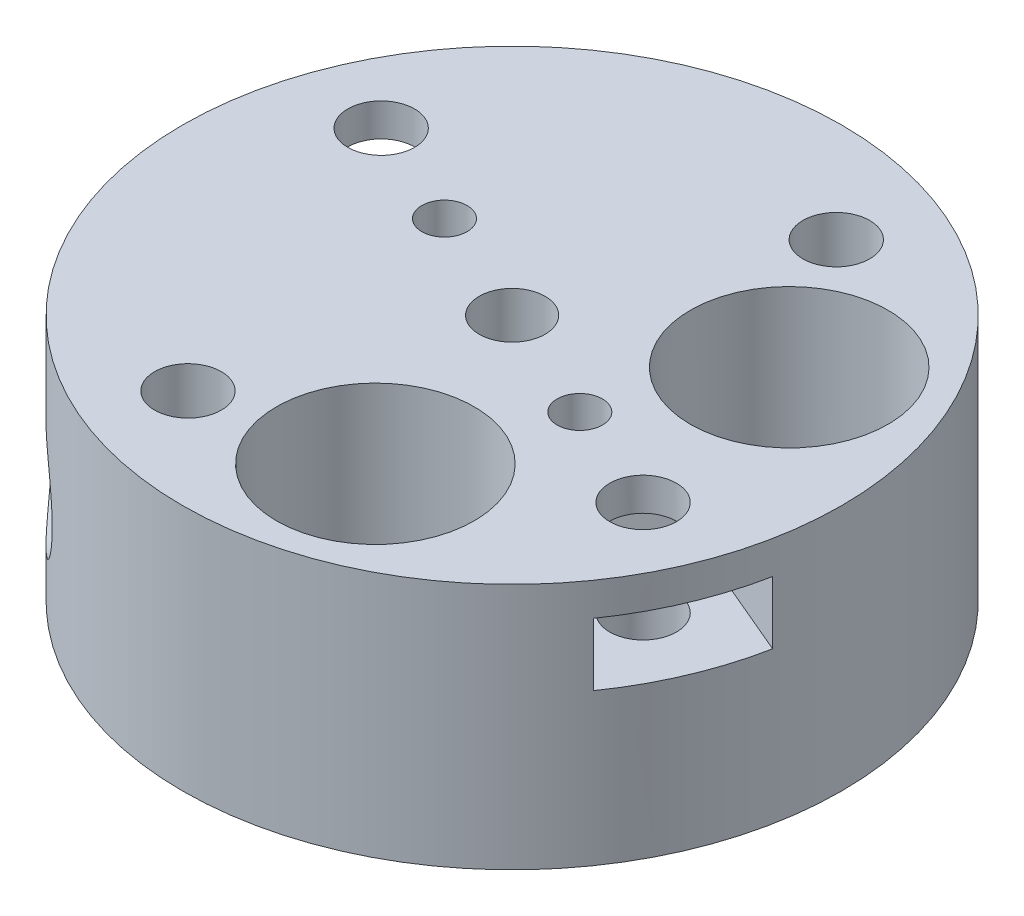
from build123d import *

# Parameters (mm, degrees)
SKETCH1_R               = 20
BOSS_EXTRUDE1_DEPTH     = 7.5
SKETCH4_R               = 5.125
CUT_EXTRUDE2_DEPTH      = 12.15
SKETCH5_R               = 2
CUT_EXTRUDE3_DEPTH      = 1
CUT_EXTRUDE3_DEPTH_BACK = 16
SKETCH2_R               = 2.025
CUT_EXTRUDE1_DEPTH      = 16
CIRPATTERN1_COUNT       = 4
SKETCH6_R               = 1.525
CUT_EXTRUDE4_DEPTH      = 21
CUT_EXTRUDE5_START      = -20
SKETCH7_R               = 3.25
CUT_EXTRUDE5_DEPTH      = 8
CUT_EXTRUDE11_START     = -6.5
CUT_EXTRUDE11_DEPTH     = 2.9
CIRPATTERN2_COUNT       = 2
CIRPATTERN2_ANGLE       = 135
CUT_EXTRUDE7_START      = 5.5
CUT_EXTRUDE7_DEPTH      = 3.8
CIRPATTERN3_COUNT       = 2
CUT_EXTRUDE12_START     = -16.0000001
SKETCH10_R              = 6
CUT_EXTRUDE12_DEPTH     = 17.0000002
CIRPATTERN4_COUNT       = 2
CIRPATTERN4_ANGLE       = 100
CUT_EXTRUDE13_START     = -16.0000001
SKETCH11_R              = 1.375
CUT_EXTRUDE13_DEPTH     = 17.0000002
SKETCH13_R              = 2.375
CUT_EXTRUDE24_DEPTH     = 12
CIRPATTERN5_COUNT       = 2


with BuildPart() as part:
    # Sketch1 → Boss-Extrude1 (new body, symmetric)
    with BuildSketch(Plane(origin=(0, 0, 0), x_dir=(1, 0, 0), z_dir=(0, 1, 0))):
        Circle(SKETCH1_R)
    extrude(amount=BOSS_EXTRUDE1_DEPTH, both=True)

    # Sketch4 → Cut-Extrude2 (cut)
    with BuildSketch(Plane.XZ.offset(7.5)):
        Circle(SKETCH4_R)
    extrude(amount=-CUT_EXTRUDE2_DEPTH, mode=Mode.SUBTRACT)

    # Sketch5 → Cut-Extrude3 (cut, two sides)
    with BuildSketch(Plane(origin=(0, 7.5, 0), x_dir=(1, 0, 0), z_dir=(0, 1, 0))) as cut_extrude3_sk:
        Circle(SKETCH5_R)
    extrude(amount=CUT_EXTRUDE3_DEPTH, mode=Mode.SUBTRACT)
    extrude(cut_extrude3_sk.sketch, amount=-CUT_EXTRUDE3_DEPTH_BACK, mode=Mode.SUBTRACT)

    # Sketch2 → Cut-Extrude1 (cut, through all)
    with BuildSketch(Plane(origin=(0, 7.5, 0), x_dir=(1, 0, 0), z_dir=(0, 1, 0))):
        with Locations((-13.807572802, 5.860966927)):
            Circle(SKETCH2_R)
    cut_extrude1 = extrude(amount=-CUT_EXTRUDE1_DEPTH, mode=Mode.SUBTRACT)

    # CirPattern1: Cut-Extrude1 ×4 about axis
    cirpattern1_axis = Axis((0, 0, 0), (0, 1, 0))
    for i in range(1, CIRPATTERN1_COUNT):
        add(cut_extrude1.rotate(cirpattern1_axis, i * 360 / CIRPATTERN1_COUNT), mode=Mode.SUBTRACT)

    # Sketch6 → Cut-Extrude4 (cut, through all)
    with BuildSketch(Plane.XY):
        with Locations((0, -1.35)):
            Circle(SKETCH6_R)
    cut_extrude4 = extrude(amount=-CUT_EXTRUDE4_DEPTH, mode=Mode.SUBTRACT)

    # Sketch7 → Cut-Extrude5 (cut)
    with BuildSketch(Plane.XY.offset(CUT_EXTRUDE5_START)):
        with Locations((0, -1.35)):
            Circle(SKETCH7_R)
    cut_extrude5 = extrude(amount=CUT_EXTRUDE5_DEPTH, mode=Mode.SUBTRACT)

    # Sketch9 → Cut-Extrude11 (cut)
    with BuildSketch(Plane.XY.offset(CUT_EXTRUDE11_START)):
        Polygon((3.15, -3.168653348), (3.15, 0.468653348), (0, 2.287306696), (-3.15, 0.468653348), (-3.15, -3.168653348), (-3.15, -7.685074736), (3.15, -7.685074736), align=None)
    cut_extrude11 = extrude(amount=-CUT_EXTRUDE11_DEPTH, mode=Mode.SUBTRACT)

    # CirPattern2: Cut-Extrude4, Cut-Extrude5, Cut-Extrude11 ×2 about axis
    cirpattern2_axis = Axis((0, 0, 0), (0, 1, 0))
    for i in range(1, CIRPATTERN2_COUNT):
        add(cut_extrude4.rotate(cirpattern2_axis, i * CIRPATTERN2_ANGLE / (CIRPATTERN2_COUNT - 1)), mode=Mode.SUBTRACT)
        add(cut_extrude5.rotate(cirpattern2_axis, i * CIRPATTERN2_ANGLE / (CIRPATTERN2_COUNT - 1)), mode=Mode.SUBTRACT)
        add(cut_extrude11.rotate(cirpattern2_axis, i * CIRPATTERN2_ANGLE / (CIRPATTERN2_COUNT - 1)), mode=Mode.SUBTRACT)

    # Sketch8 → Cut-Extrude7 (cut)
    with BuildSketch(Plane(origin=(0, 0, 0), x_dir=(1, 0, 0), z_dir=(0, 1, 0)).offset(CUT_EXTRUDE7_START)):
        Polygon((-9.396506885, 3.988580533), (-9.98050566, 8.744868872), (-14.391571577, 10.617255266), (-19.569899143, 12.815324908), (-22.81296751, 5.175134625), (-17.634639943, 2.977064983), (-13.223574027, 1.104678588), align=None)
    cut_extrude7 = extrude(amount=-CUT_EXTRUDE7_DEPTH, mode=Mode.SUBTRACT)

    # CirPattern3: Cut-Extrude7 ×2 about axis
    cirpattern3_axis = Axis((0, 0, 0), (0, 1, 0))
    for i in range(1, CIRPATTERN3_COUNT):
        add(cut_extrude7.rotate(cirpattern3_axis, i * 360 / CIRPATTERN3_COUNT), mode=Mode.SUBTRACT)

    # Sketch10 → Cut-Extrude12 (cut)
    with BuildSketch(Plane(origin=(0, 7.5, 0), x_dir=(1, 0, 0), z_dir=(0, 1, 0)).offset(CUT_EXTRUDE12_START)):
        with Locations((3.654646309, -11.95380945)):
            Circle(SKETCH10_R)
    cut_extrude12 = extrude(amount=CUT_EXTRUDE12_DEPTH, mode=Mode.SUBTRACT)

    # CirPattern4: Cut-Extrude12 ×2 about axis
    cirpattern4_axis = Axis((0, 7.5, 0), (0, 1, 0))
    for i in range(1, CIRPATTERN4_COUNT):
        add(cut_extrude12.rotate(cirpattern4_axis, i * CIRPATTERN4_ANGLE / (CIRPATTERN4_COUNT - 1)), mode=Mode.SUBTRACT)

    # Sketch11 → Cut-Extrude13 (cut)
    with BuildSketch(Plane(origin=(0, 7.5, 0), x_dir=(1, 0, 0), z_dir=(0, 1, 0)).offset(CUT_EXTRUDE13_START)):
        with Locations((7.133912614, -3.028166246)):
            Circle(SKETCH11_R)
    cut_extrude13 = extrude(amount=CUT_EXTRUDE13_DEPTH, mode=Mode.SUBTRACT)

    # Sketch13 → Cut-Extrude24 (cut)
    with BuildSketch(Plane(origin=(0, -7.5, 0), x_dir=(-1, 0, 0), z_dir=(0, -1, 0))):
        with Locations((-7.133912614, -3.028166246)):
            Circle(SKETCH13_R)
    cut_extrude24 = extrude(amount=-CUT_EXTRUDE24_DEPTH, mode=Mode.SUBTRACT)

    # CirPattern5: Cut-Extrude13, Cut-Extrude24 ×2 about axis
    cirpattern5_axis = Axis((0, 0, 0), (0, 1, 0))
    for i in range(1, CIRPATTERN5_COUNT):
        add(cut_extrude13.rotate(cirpattern5_axis, i * 360 / CIRPATTERN5_COUNT), mode=Mode.SUBTRACT)
        add(cut_extrude24.rotate(cirpattern5_axis, i * 360 / CIRPATTERN5_COUNT), mode=Mode.SUBTRACT)


solid = part.part
